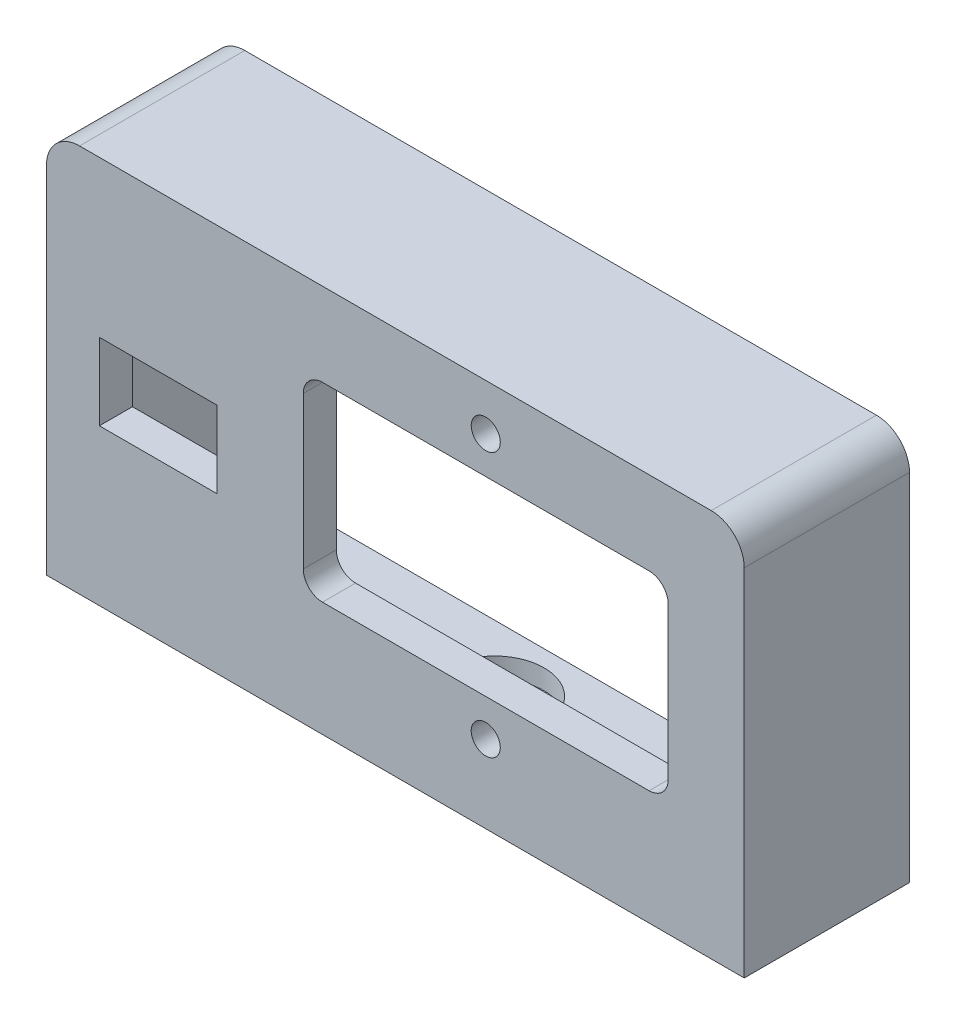
from build123d import *

# Parameters (mm, degrees)
ESBO_O1_W                                      = 105.544372836
ESBO_O1_H                                      = 58.736189027
ESBO_O1_R                                      = 2.2
RESSALTO_EXTRUS_O1_DEPTH                       = 5
ESBO_O2_W                                      = 17.8
ESBO_O2_H                                      = 11.6
CORTE_EXTRUS_O1_DEPTH                          = 10
FILETE1_R                                      = 5
RESSALTO_EXTRUS_O2_DEPTH                       = 20
BROCA_DE_ROSQUEAR_PARA_TARRAXA_DE_M3X0_5_D     = 2.5
BROCA_DE_ROSQUEAR_PARA_TARRAXA_DE_M3X0_5_DEPTH = 3
ESBO_O4_R                                      = 7.5
CORTE_EXTRUS_O2_DEPTH                          = 10


with BuildPart() as part:
    # Esboço1 → Ressalto-extrusão1 (new body)
    with BuildSketch(Plane.XY):
        with Locations((4.903986461, -60.193985815)):
            Rectangle(ESBO_O1_W, ESBO_O1_H)
        with Locations((18.576172879, -37.825891301)):
            Circle(ESBO_O1_R, mode=Mode.SUBTRACT)
        with Locations((18.576172879, -77.825891301)):
            Circle(ESBO_O1_R, mode=Mode.SUBTRACT)
        with BuildLine():
            Line((43.276172879, -43.425891301), (-6.123827121, -43.425891301))
            ThreePointArc((-6.123827121, -43.425891301), (-8.174436786, -44.275281636), (-9.023827121, -46.325891301))
            Line((-9.023827121, -46.325891301), (-9.023827121, -69.325891301))
            ThreePointArc((-9.023827121, -69.325891301), (-8.174436786, -71.376500966), (-6.123827121, -72.225891301))
            Line((-6.123827121, -72.225891301), (43.276172879, -72.225891301))
            ThreePointArc((43.276172879, -72.225891301), (45.326782544, -71.376500966), (46.176172879, -69.325891301))
            Line((46.176172879, -69.325891301), (46.176172879, -46.325891301))
            ThreePointArc((46.176172879, -46.325891301), (45.326782544, -44.275281636), (43.276172879, -43.425891301))
        make_face(mode=Mode.SUBTRACT)
    extrude(amount=RESSALTO_EXTRUS_O1_DEPTH)

    # Esboço2 → Corte-extrusão1 (cut)
    with BuildSketch(Plane.XY.offset(5)):
        with Locations((-30.968199957, -60.193985814)):
            Rectangle(ESBO_O2_W, ESBO_O2_H)
    extrude(amount=-CORTE_EXTRUS_O1_DEPTH, mode=Mode.SUBTRACT)

    # Filete1
    filete1_edges = [part.edges().sort_by_distance(p)[0] for p in [
        (-47.868199957, -30.825891301, 2.5),
        (57.676172879, -30.825891301, 2.5),
    ]]
    fillet(filete1_edges, radius=FILETE1_R)

    # Esboço3 → Ressalto-extrusão2 (add)
    with BuildSketch(Plane(origin=(0, 0, 0), x_dir=(-1, 0, 0), z_dir=(0, 0, -1))):
        with BuildLine():
            Line((42.868199957, -30.825891301), (-52.676172879, -30.825891301))
            ThreePointArc((-52.676172879, -30.825891301), (-56.211706785, -32.290357395), (-57.676172879, -35.825891301))
            Line((-57.676172879, -35.825891301), (-57.676172879, -89.562080328))
            Line((-57.676172879, -89.562080328), (47.868199957, -89.562080328))
            Line((47.868199957, -89.562080328), (47.868199957, -35.825891301))
            ThreePointArc((47.868199957, -35.825891301), (46.403733863, -32.290357395), (42.868199957, -30.825891301))
        make_face()
        with BuildLine():
            Line((42.868199957, -33.825891301), (-52.676172879, -33.825891301))
            ThreePointArc((-52.676172879, -33.825891301), (-54.090386441, -34.411677739), (-54.676172879, -35.825891301))
            Line((-54.676172879, -35.825891301), (-54.676172879, -86.562080328))
            Line((-54.676172879, -86.562080328), (44.868199957, -86.562080328))
            Line((44.868199957, -86.562080328), (44.868199957, -35.825891301))
            ThreePointArc((44.868199957, -35.825891301), (44.282413519, -34.411677739), (42.868199957, -33.825891301))
        make_face(mode=Mode.SUBTRACT)
    extrude(amount=RESSALTO_EXTRUS_O2_DEPTH)

    # Broca de rosquear para tarraxa de M3x0.51
    with Locations(Plane(origin=(0, -86.562080328, 0), x_dir=(1, 0, 0), z_dir=(0, 1, 0))):
        with Locations((29.645811084, 10.02860531), (-19.913744381, 10.02860531)):
            Hole(BROCA_DE_ROSQUEAR_PARA_TARRAXA_DE_M3X0_5_D / 2, depth=BROCA_DE_ROSQUEAR_PARA_TARRAXA_DE_M3X0_5_DEPTH)

    # Esboço4 → Corte-extrusão2 (cut)
    with BuildSketch(Plane(origin=(0, -86.562080328, 0), x_dir=(1, 0, 0), z_dir=(0, 1, 0))):
        with Locations((4.903986461, 10)):
            Circle(ESBO_O4_R)
    extrude(amount=-CORTE_EXTRUS_O2_DEPTH, mode=Mode.SUBTRACT)


solid = part.part
